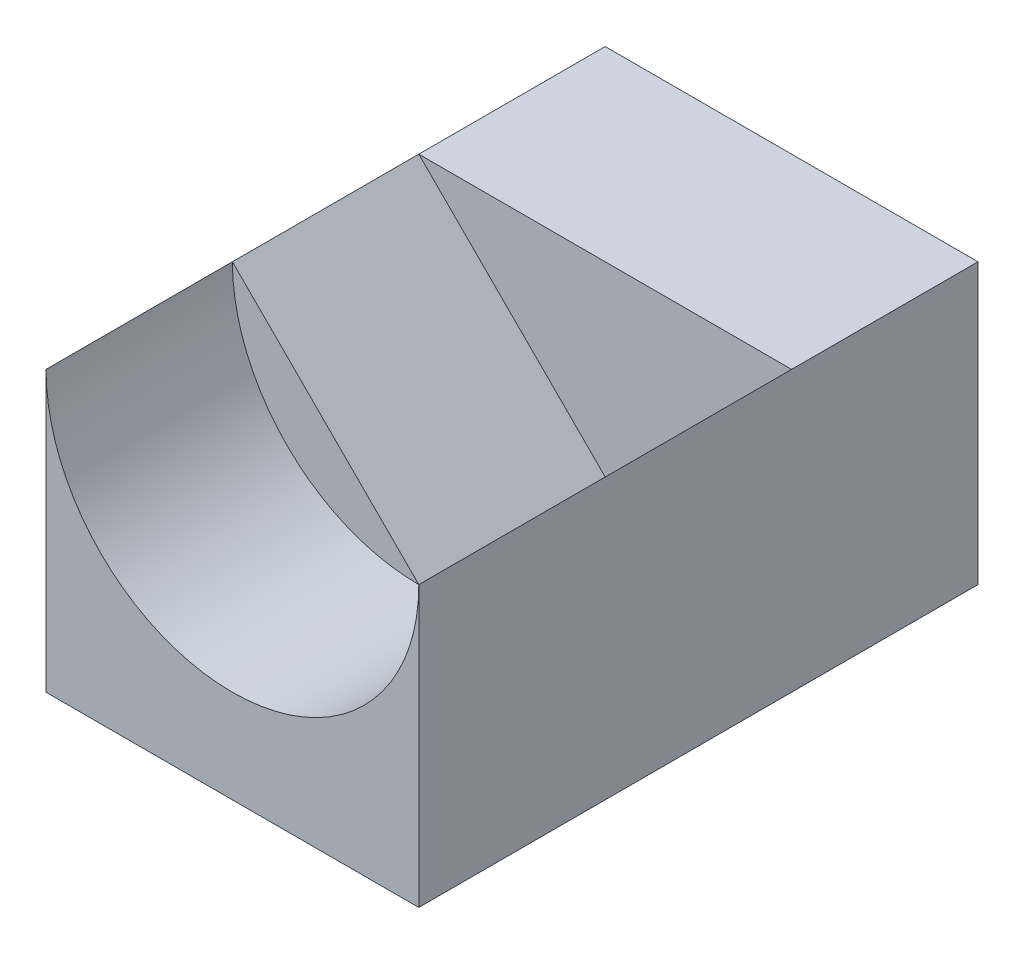
from build123d import *

# Parameters (mm, degrees)
SKETCH_1_W          = 20
SKETCH_1_H          = 30
EXTRUDE_1_DEPTH     = 15
CUT_EXTRUDE_1_DEPTH = 10
CUT_EXTRUDE_2_DEPTH = 10


with BuildPart() as part:
    # 草圖1 → 填料-伸長1 (new body)
    with BuildSketch(Plane(origin=(0, 0, 0), x_dir=(1, 0, 0), z_dir=(0, 1, 0))):
        Rectangle(SKETCH_1_W, SKETCH_1_H)
    extrude(amount=EXTRUDE_1_DEPTH)

    # 草圖2 → 除料-伸長1 (cut)
    with BuildSketch(Plane.XY.offset(15)):
        with BuildLine():
            Line((10, 15), (-10, 15))
            ThreePointArc((-10, 15), (0, 5), (10, 15))
        make_face()
    extrude(amount=-CUT_EXTRUDE_1_DEPTH, mode=Mode.SUBTRACT)

    # 草圖3 → 除料-伸長2 (cut)
    with BuildSketch(Plane.XY.offset(5)):
        Polygon((-10, 15), (0, 5), (10, 15), align=None)
    extrude(amount=-CUT_EXTRUDE_2_DEPTH, mode=Mode.SUBTRACT)


solid = part.part
